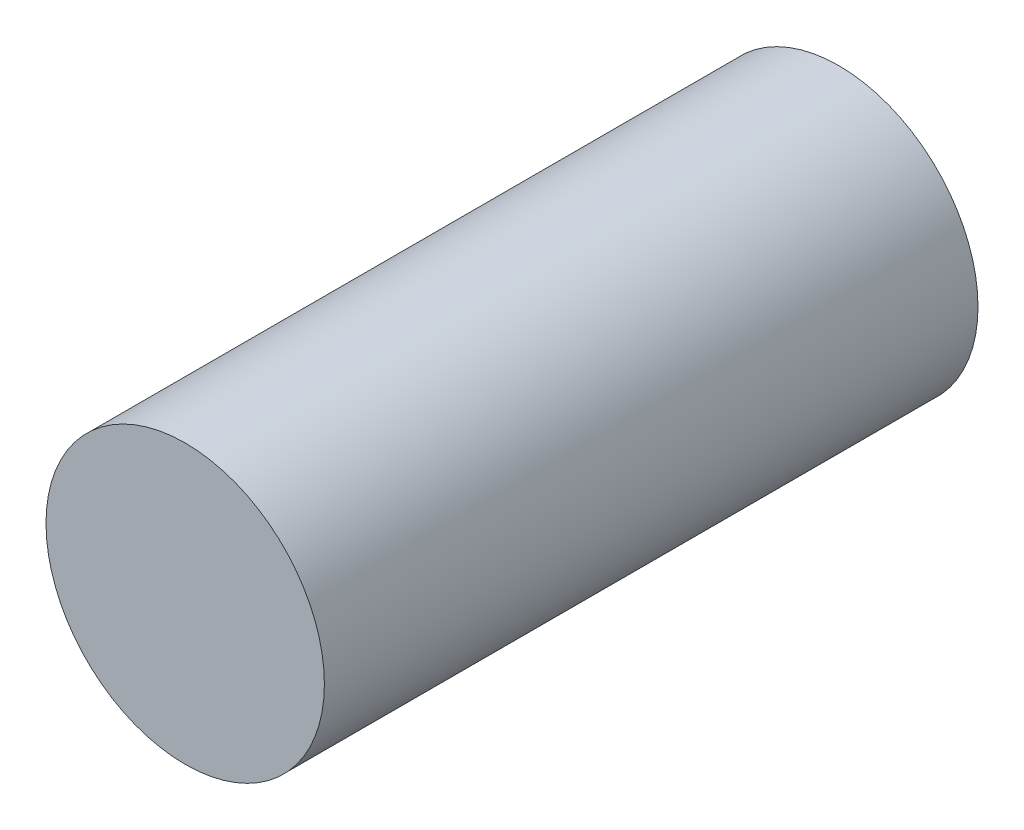
from build123d import *

# Parameters (mm, degrees)
ESQUISSE1_R        = 5.75
BOSS_EXTRU_1_DEPTH = 13.5


with BuildPart() as part:
    # Esquisse1 → Boss.-Extru.1 (new body, symmetric)
    with BuildSketch(Plane.XY):
        Circle(ESQUISSE1_R)
    extrude(amount=BOSS_EXTRU_1_DEPTH, both=True)


solid = part.part
